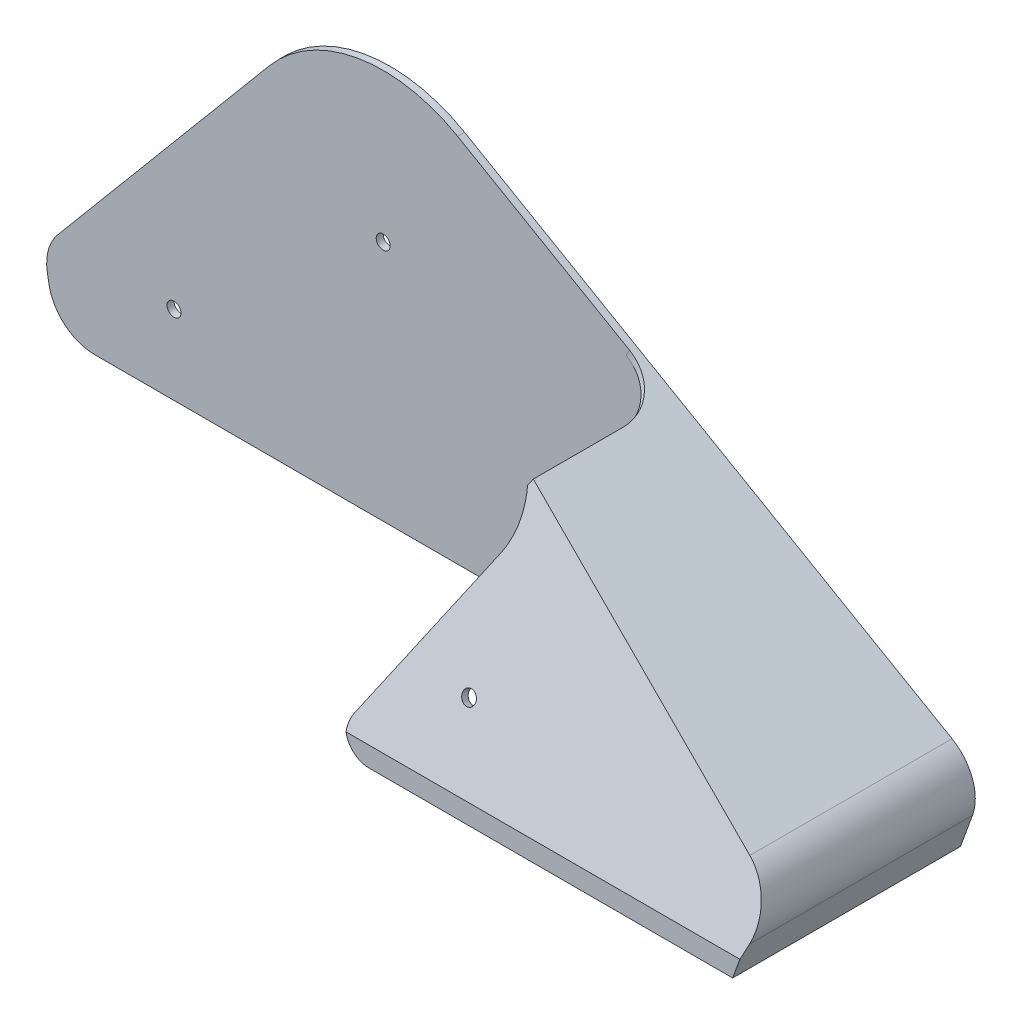
from build123d import *

# Parameters (mm, degrees)
SKETCH_1_R          = 1.5
EXTRUDE_1_DEPTH     = 46
SKETCH_6_W          = 244.099615043
SKETCH_6_H          = 133.346377704
CUT_EXTRUDE_3_DEPTH = 339.792470358
SHELL_1_T           = 1.5
CUT_EXTRUDE_START   = -1.5
CUT_EXTRUDE_2_DEPTH = 342.316954288
FILLET_2_R          = 10
FILLET_3_R          = 10
FILLET_4_R          = 5
SKETCH_7_W          = 1.712142643
SKETCH_7_H          = 34.810742179
CUT_EXTRUDE_4_DEPTH = 5
FILLET_5_R          = 10
SKETCH_10_R         = 1.5
CUT_EXTRUDE_5_DEPTH = 2
SKETCH_11_R         = 1.5
CUT_EXTRUDE_6_DEPTH = 2


with BuildPart() as part:
    # 草图1 → 凸台-拉伸1 (new body)
    with BuildSketch(Plane.XY):
        with BuildLine():
            Line((-186.419017908, -172.076823512), (-234.49796572, -229.375082296))
            Line((-234.49796572, -229.375082296), (-231.975297342, -243.681845608))
            Line((-231.975297342, -243.681845608), (-41.975297342, -243.681845608))
            Line((-41.975297342, -243.681845608), (-36.768061348, -229.375082296))
            Line((-36.768061348, -229.375082296), (-147.804662393, -165.268070792))
            ThreePointArc((-147.804662393, -165.268070792), (-168.350931812, -161.645209141), (-186.419017908, -172.076823512))
        make_face()
        with Locations((-163.054662393, -191.681845608)):
            Circle(SKETCH_1_R, mode=Mode.SUBTRACT)
    extrude(amount=EXTRUDE_1_DEPTH)

    # 草图6 → 切除-拉伸3 (cut, through all)
    with BuildSketch(Plane(origin=(0, -13.84451284, -37.461622979), x_dir=(1, 0, 0), z_dir=(0, 0.3466501408716292, 0.9379944988291136))):
        with Locations((-134.599820809, -204.098171804)):
            Rectangle(SKETCH_6_W, SKETCH_6_H)
    extrude(amount=CUT_EXTRUDE_3_DEPTH, mode=Mode.SUBTRACT)

    # 抽壳1
    shell_1_openings = [part.faces().sort_by_distance(p)[0] for p in [
        (-136.975297342, -243.681845608, 23),
        (-164.554662393, -191.681845608, 14.463541988),
    ]]
    offset(amount=SHELL_1_T, openings=shell_1_openings, kind=Kind.INTERSECTION)

    # 草图2 → 切除-拉伸2 (cut, through all)
    with BuildSketch(Plane(origin=(0, 0, -1.5), x_dir=(-1, 0, 0), z_dir=(0, 0, -1)).offset(CUT_EXTRUDE_START)):
        with BuildLine():
            Line((103.691214377, -202.861337532), (127.258945703, -243.681845608))
            Line((127.258945703, -243.681845608), (233.49843726, -243.681845608))
            Line((233.49843726, -243.681845608), (236.096637562, -228.946719467))
            Line((236.096637562, -228.946719467), (187.568084573, -171.112642098))
            ThreePointArc((187.568084573, -171.112642098), (168.611404078, -160.167997512), (147.054662393, -163.969032687))
            Line((147.054662393, -163.969032687), (102.8873668, -189.469032687))
            ThreePointArc((102.8873668, -189.469032687), (101.708543429, -196.260066445), (103.691214377, -202.861337532))
        make_face()
    extrude(amount=-CUT_EXTRUDE_2_DEPTH, mode=Mode.SUBTRACT)

    # 圆角2
    fillet_2_edges = [part.edges().sort_by_distance(p)[0] for p in [
        (-34.928038952, -228.705368914, 21.021316252),
        (-36.768061348, -229.375082296, 21.095489388),
    ]]
    fillet(fillet_2_edges, radius=FILLET_2_R)

    # 圆角3
    fillet_3_edges = [part.edges().sort_by_distance(p)[0] for p in [
        (-236.096637562, -228.946719467, -0.75),
        (-233.49843726, -243.681845608, -0.75),
    ]]
    fillet(fillet_3_edges, radius=FILLET_3_R)

    # 圆角4
    fillet_4_edges = [part.edges().sort_by_distance(p)[0] for p in [
        (-127.258945703, -243.681845608, 46.75),
    ]]
    fillet(fillet_4_edges, radius=FILLET_4_R)

    # 草图7 → 切除-拉伸4 (cut)
    with BuildSketch(Plane(origin=(-107.764339469, -186.653311204, 0), x_dir=(0.8660254037844399, -0.4999999999999979, 0), z_dir=(0.49999999999999784, 0.8660254037844398, 0))):
        with Locations((6.487514288, -17.40537109)):
            Rectangle(SKETCH_7_W, SKETCH_7_H)
    extrude(amount=-CUT_EXTRUDE_4_DEPTH, mode=Mode.SUBTRACT)

    # 圆角5
    fillet_5_edges = [part.edges().sort_by_distance(p)[0] for p in [
        (-101.779607776, -190.974623061, 0),
    ]]
    fillet(fillet_5_edges, radius=FILLET_5_R)

    # 草图10 → 切除-拉伸5 (cut)
    with BuildSketch(Plane(origin=(0, 0, -1.5), x_dir=(-1, 0, 0), z_dir=(0, 0, -1))):
        with Locations((208.054662393, -226.681845608)):
            Circle(SKETCH_10_R)
        with Locations((63.054662393, -226.681845608)):
            Circle(SKETCH_10_R)
    extrude(amount=-CUT_EXTRUDE_5_DEPTH, mode=Mode.SUBTRACT)

    # 草图11 → 切除-拉伸6 (cut)
    with BuildSketch(Plane(origin=(0, -13.324537629, -36.054631231), x_dir=(1, 0, 0), z_dir=(0, 0.3466501408716292, 0.9379944988291135))):
        with Locations(Location((-102.379030683, -225.76615913, 0), (0, 0, 270))):
            Circle(SKETCH_11_R)
    extrude(amount=-CUT_EXTRUDE_6_DEPTH, mode=Mode.SUBTRACT)


solid = part.part
